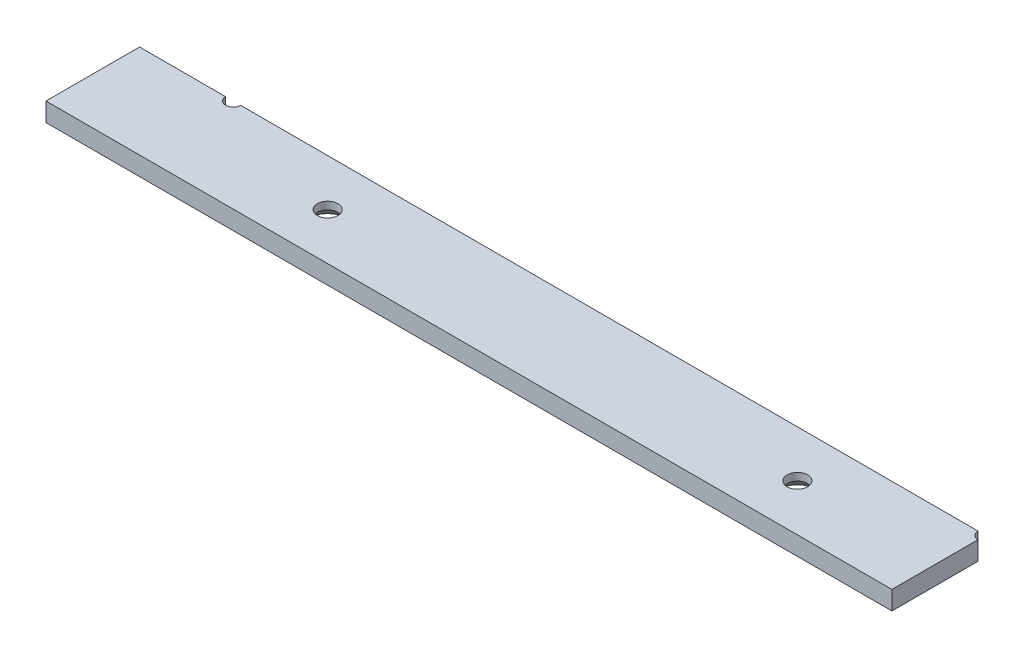
from build123d import *

# Parameters (mm, degrees)
CROQUIS1_W                                           = 226
CROQUIS1_H                                           = 25
SALIENTE_EXTRUIR1_DEPTH                              = 5
CROQUIS2_R                                           = 2
CORTAR_EXTRUIR1_DEPTH                                = 5
AVELLANADO_PARA_TORNILLO_CON_CABEZA_AVEL_D           = 5.5
AVELLANADO_PARA_TORNILLO_CON_CABEZA_AVEL_DEPTH       = 5
AVELLANADO_PARA_TORNILLO_CON_CABEZA_AVEL_CSINK_D     = 11.47
AVELLANADO_PARA_TORNILLO_CON_CABEZA_AVEL_CSINK_ANGLE = 90
AVELLANADO_PARA_TORNILLO_CON_CABEZA_AVEL_TIP         = 1.652366702


with BuildPart() as part:
    # Croquis1 → Saliente-Extruir1 (new body)
    with BuildSketch(Plane(origin=(0, 0, 0), x_dir=(1, 0, 0), z_dir=(0, 1, 0))):
        with Locations((113, 12.5)):
            Rectangle(CROQUIS1_W, CROQUIS1_H)
    extrude(amount=SALIENTE_EXTRUIR1_DEPTH)

    # Croquis2 → Cortar-Extruir1 (cut)
    with BuildSketch(Plane(origin=(0, 5, 0), x_dir=(1, 0, 0), z_dir=(0, 1, 0))):
        with Locations((25, 25)):
            Circle(CROQUIS2_R)
        with Locations((226, 25)):
            Circle(CROQUIS2_R)
    extrude(amount=-CORTAR_EXTRUIR1_DEPTH, mode=Mode.SUBTRACT)

    # Avellanado para tornillo con cabeza avellanada de clavija hexagonal de M51
    with Locations(Plane(origin=(0, 0, 0), x_dir=(-1, 0, 0), z_dir=(0, -1, 0))):
        with Locations((-62.75, 12.5), (-188.25, 12.5)):
            CounterSinkHole(AVELLANADO_PARA_TORNILLO_CON_CABEZA_AVEL_D / 2, AVELLANADO_PARA_TORNILLO_CON_CABEZA_AVEL_CSINK_D / 2, depth=AVELLANADO_PARA_TORNILLO_CON_CABEZA_AVEL_DEPTH, counter_sink_angle=AVELLANADO_PARA_TORNILLO_CON_CABEZA_AVEL_CSINK_ANGLE)
            with Locations((0, 0, -(AVELLANADO_PARA_TORNILLO_CON_CABEZA_AVEL_DEPTH + AVELLANADO_PARA_TORNILLO_CON_CABEZA_AVEL_TIP / 2))):  # 118° drill point
                Cone(0, AVELLANADO_PARA_TORNILLO_CON_CABEZA_AVEL_D / 2, AVELLANADO_PARA_TORNILLO_CON_CABEZA_AVEL_TIP, mode=Mode.SUBTRACT)


solid = part.part
